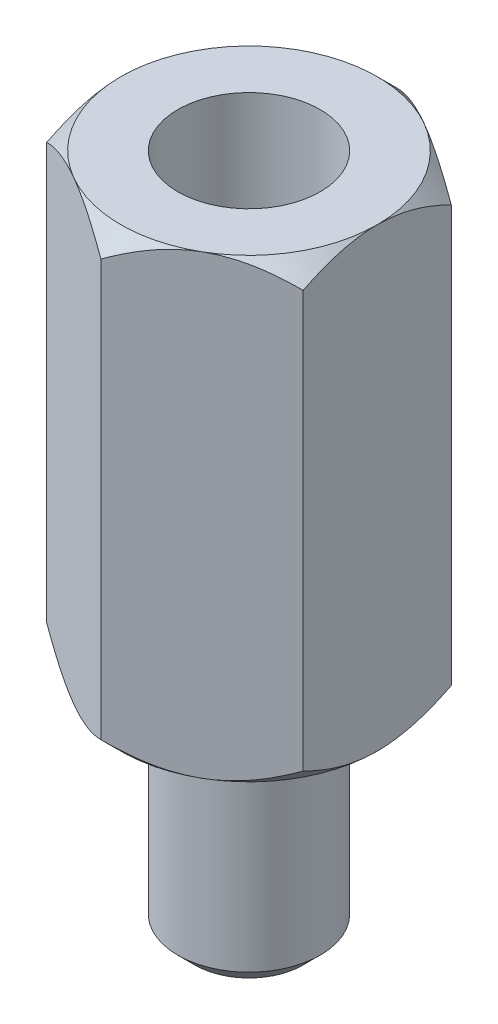
from build123d import *

# Parameters (mm, degrees)
SKETCH1_R           = 1.25
BOSS_EXTRUDE1_DEPTH = 3.9
BOSS_EXTRUDE2_DEPTH = 8
SKETCH3_R           = 1.25
CUT_EXTRUDE1_DEPTH  = 4.8
SKETCH4_OUTSIDE_W   = 35.048
SKETCH4_OUTSIDE_H   = 35.744
SKETCH4_OUTSIDE_R   = 2.25
CUT_EXTRUDE2_DEPTH  = 12.9
CUT_EXTRUDE2_TAPER  = 45
SKETCH5_OUTSIDE_W   = 27.248
SKETCH5_OUTSIDE_H   = 27.944
SKETCH5_OUTSIDE_R   = 2.25
CUT_EXTRUDE3_DEPTH  = 9
CUT_EXTRUDE3_TAPER  = 45
CHAMFER1_SIZE       = 0.3


with BuildPart() as part:
    # Sketch1 → Boss-Extrude1 (new body)
    with BuildSketch(Plane(origin=(0, 0, 0), x_dir=(1, 0, 0), z_dir=(0, 1, 0))):
        Circle(SKETCH1_R)
    extrude(amount=BOSS_EXTRUDE1_DEPTH)

    # Sketch2 → Boss-Extrude2 (add)
    with BuildSketch(Plane(origin=(0, 3.9, 0), x_dir=(1, 0, 0), z_dir=(0, 1, 0))):
        Polygon((0, -2.598076211), (2.25, -1.299038106), (2.25, 1.299038106), (0, 2.598076211), (-2.25, 1.299038106), (-2.25, -1.299038106), align=None)
    extrude(amount=BOSS_EXTRUDE2_DEPTH)

    # Sketch3 → Cut-Extrude1 (cut)
    with BuildSketch(Plane(origin=(0, 11.9, 0), x_dir=(1, 0, 0), z_dir=(0, 1, 0))):
        Circle(SKETCH3_R)
    extrude(amount=-CUT_EXTRUDE1_DEPTH, mode=Mode.SUBTRACT)

    # Sketch4 outside → Cut-Extrude2 (cut, through all)
    with BuildSketch(Plane(origin=(0, 11.9, 0), x_dir=(1, 0, 0), z_dir=(0, 1, 0))):
        Rectangle(SKETCH4_OUTSIDE_W, SKETCH4_OUTSIDE_H)
        Circle(SKETCH4_OUTSIDE_R, mode=Mode.SUBTRACT)
    extrude(amount=-CUT_EXTRUDE2_DEPTH, taper=CUT_EXTRUDE2_TAPER, mode=Mode.SUBTRACT)

    # Sketch5 outside → Cut-Extrude3 (cut, through all)
    with BuildSketch(Plane.XZ.offset(-3.9)):
        Rectangle(SKETCH5_OUTSIDE_W, SKETCH5_OUTSIDE_H)
        Circle(SKETCH5_OUTSIDE_R, mode=Mode.SUBTRACT)
    extrude(amount=-CUT_EXTRUDE3_DEPTH, taper=CUT_EXTRUDE3_TAPER, mode=Mode.SUBTRACT)

    # Chamfer1
    chamfer1_edges = [part.edges().sort_by_distance(p)[0] for p in [
        (-1.25, 0, 0),
    ]]
    chamfer(chamfer1_edges, length=CHAMFER1_SIZE)


solid = part.part
